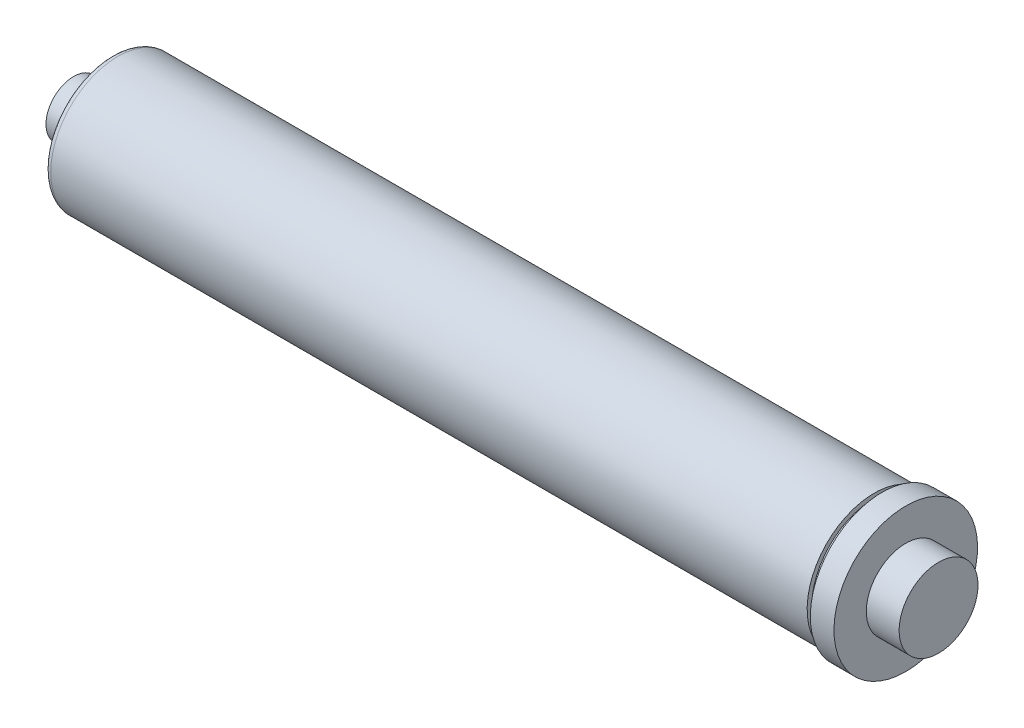
from build123d import *

# Parameters (mm, degrees)
FILLET1_R          = 2.54
SKETCH2_R          = 7.62
CUT_EXTRUDE1_DEPTH = 6.35
SKETCH3_R          = 1.5875
CUT_EXTRUDE2_DEPTH = 6.35


with BuildPart() as part:
    # Sketch1 → Revolve1 (revolve)
    with BuildSketch(Plane.XY):
        Polygon((0, 0), (0, 11.1125), (15.24, 11.1125), (15.24, 26.9875), (322.199, 26.9875), (322.199, 25.1714), (325.374, 25.1714), (325.374, 28.8925), (334.899, 28.8925), (334.899, 15.875), (348.107, 15.875), (348.107, 0), align=None)
    revolve(axis=Axis((0, 0, 0), (1, 0, 0)))

    # Fillet1
    fillet1_edges = [part.edges().sort_by_distance(p)[0] for p in [
        (15.24, -26.9875, 0),
    ]]
    fillet(fillet1_edges, radius=FILLET1_R)

    # Sketch2 → Cut-Extrude1 (cut)
    with BuildSketch(Plane.ZY):
        Circle(SKETCH2_R)
    extrude(amount=-CUT_EXTRUDE1_DEPTH, mode=Mode.SUBTRACT)

    # Sketch3 → Cut-Extrude2 (cut)
    with BuildSketch(Plane.ZY.offset(-6.35)):
        Circle(SKETCH3_R)
    extrude(amount=-CUT_EXTRUDE2_DEPTH, mode=Mode.SUBTRACT)


solid = part.part
